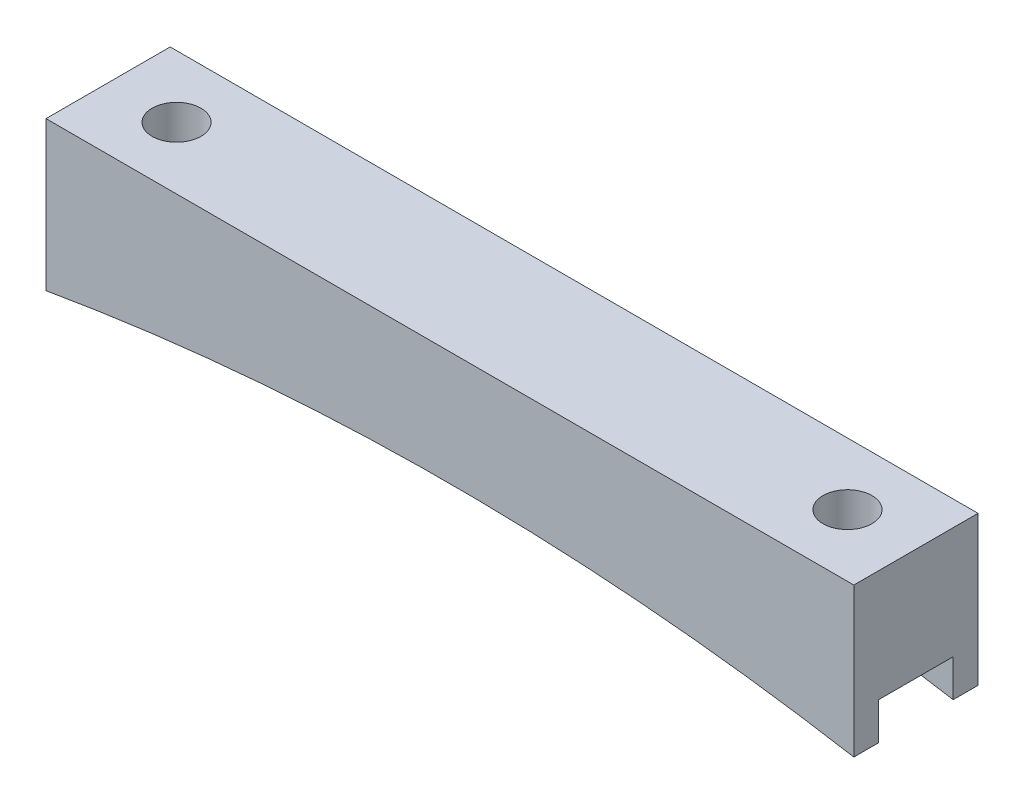
from build123d import *

# Parameters (mm, degrees)
BOSS_EXTRUDE1_DEPTH = 12.7
SKETCH2_R           = 2.5
CUT_EXTRUDE1_DEPTH  = 16.24
SKETCH3_W           = 7.62
SKETCH3_H           = 3.81
CUT_EXTRUDE2_DEPTH  = 83.6200001


with BuildPart() as part:
    # Sketch1 → Boss-Extrude1 (new body)
    with BuildSketch(Plane.XY):
        with BuildLine():
            Line((-41.31, 0), (41.31, 0))
            Line((41.31, 0), (41.31, -15.24))
            ThreePointArc((41.31, -15.24), (0, -11.677615661), (-41.31, -15.24))
            Line((-41.31, -15.24), (-41.31, 0))
        make_face()
    extrude(amount=BOSS_EXTRUDE1_DEPTH)

    # Sketch2 → Cut-Extrude1 (cut, through all)
    with BuildSketch(Plane(origin=(0, 0, 0), x_dir=(1, 0, 0), z_dir=(0, 1, 0))):
        with Locations((-34.31, -6.35)):
            Circle(SKETCH2_R)
        with Locations((34.31, -6.35)):
            Circle(SKETCH2_R)
    extrude(amount=-CUT_EXTRUDE1_DEPTH, mode=Mode.SUBTRACT)

    # Sketch3 → Cut-Extrude2 (cut, through all)
    with BuildSketch(Plane(origin=(41.31, 0, 0), x_dir=(0, 0, -1), z_dir=(1, 0, 0))):
        with Locations((-6.35, -13.335)):
            Rectangle(SKETCH3_W, SKETCH3_H)
    extrude(amount=-CUT_EXTRUDE2_DEPTH, mode=Mode.SUBTRACT)


solid = part.part
